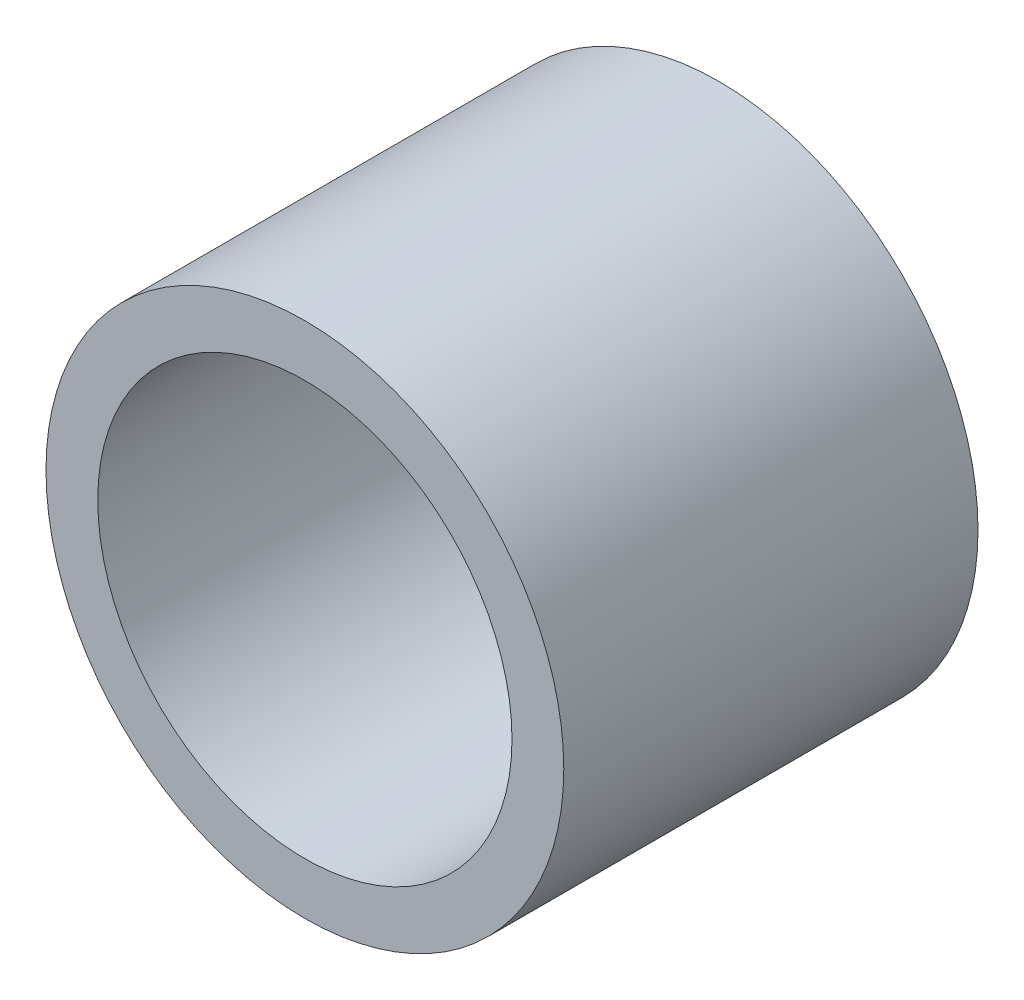
from build123d import *

# Parameters (mm, degrees)
SKETCH1_W = 0.79375
SKETCH1_H = 6.35


with BuildPart() as part:
    # Sketch1 → Revolve1 (revolve)
    with BuildSketch(Plane.XZ):
        with Locations((3.571875, 0)):
            Rectangle(SKETCH1_W, SKETCH1_H)
    revolve(axis=Axis((0, 0, 3.175), (0, 0, -1)))


solid = part.part
